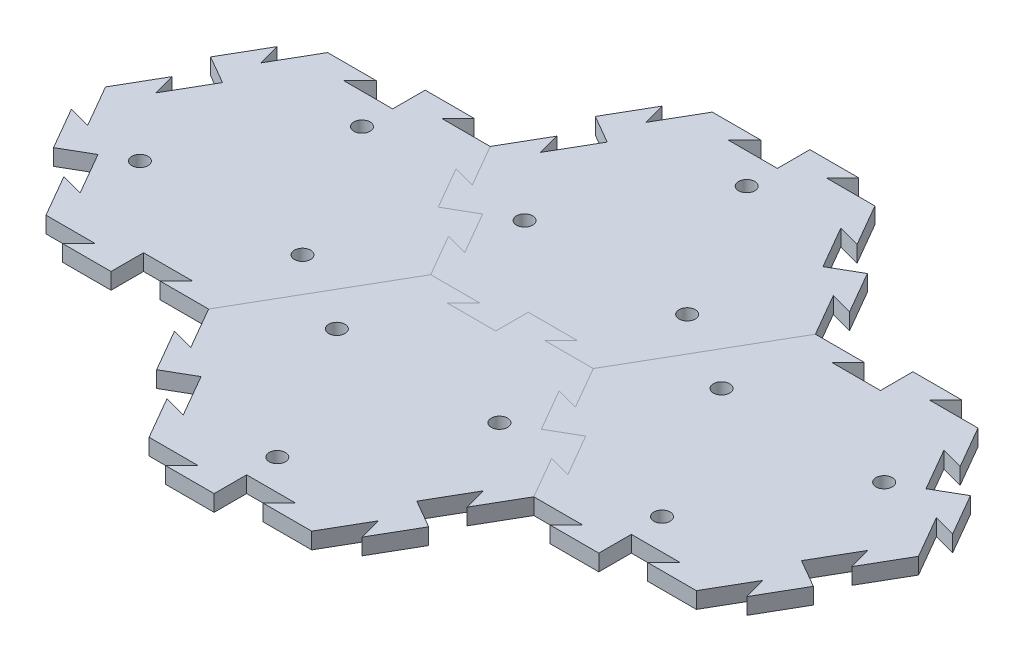
from build123d import *

# Parameters (mm, degrees)
BOSS_EXTRUDE1_DEPTH = 6.35
SKETCH9_R           = 3.175
CUT_EXTRUDE3_DEPTH  = 85.242269675
CIRPATTERN6_COUNT   = 3
CUT_EXTRUDE4_DEPTH  = 194.232075495
BOSS_EXTRUDE4_DEPTH = 6.35
CIRPATTERN7_COUNT   = 6
CUT_EXTRUDE5_DEPTH  = 194.232075495
BOSS_EXTRUDE5_DEPTH = 6.35
CIRPATTERN8_COUNT   = 6
LPATTERN1_COUNT     = 2
LPATTERN1_PITCH     = 109.985226308


with BuildPart() as part:
    # Sketch1 → Boss-Extrude1 (new body)
    with BuildSketch(Plane(origin=(0, 0, 0), x_dir=(1, 0, 0), z_dir=(0, 1, 0))):
        Polygon((63.5, 0), (31.75, 54.99261314), (-31.75, 54.99261314), (-63.5, 0), (-31.75, -54.99261314), (31.75, -54.99261314), align=None)
    extrude(amount=-BOSS_EXTRUDE1_DEPTH)

    # Sketch9 → Cut-Extrude3 (cut, through all)
    with BuildSketch(Plane(origin=(0, 0, 0), x_dir=(1, 0, 0), z_dir=(0, 1, 0))):
        with Locations((-31.75, -18.330871047)):
            Circle(SKETCH9_R)
    cut_extrude3 = extrude(amount=-CUT_EXTRUDE3_DEPTH, mode=Mode.SUBTRACT)

    # CirPattern6: Cut-Extrude3 ×3 about axis
    cirpattern6_axis = Axis((0, 0, 0), (0, 1, 0))
    for i in range(1, CIRPATTERN6_COUNT):
        add(cut_extrude3.rotate(cirpattern6_axis, i * 360 / CIRPATTERN6_COUNT), mode=Mode.SUBTRACT)


with BuildPart() as body_2:
    # Mirror3: mirrored copy
    add(part.part.mirror(Plane(origin=(31.75, -6.35, 54.99261314), x_dir=(-0.4999999999999997, 0, 0.8660254037844387), z_dir=(0.8660254037844387, 0, 0.49999999999999983))))

    # Sketch13 → Cut-Extrude5 (cut, through all)
    with BuildSketch(Plane(origin=(0, 0, 0), x_dir=(1, 0, 0), z_dir=(0, 1, 0))):
        Polygon((136.525, -16.497783942), (127.850738686, -14.173522628), (137.375738686, -30.67130657), (142.875, -27.49630657), align=None)
    cut_extrude5 = extrude(amount=-CUT_EXTRUDE5_DEPTH, mode=Mode.SUBTRACT)

    # Sketch14 → Boss-Extrude5 (add)
    with BuildSketch(Plane(origin=(0, 0, 0), x_dir=(1, 0, 0), z_dir=(0, 1, 0))):
        Polygon((142.875, -27.49630657), (148.374261314, -24.32130657), (157.899261314, -40.819090512), (149.225, -38.494829198), align=None)
    boss_extrude5 = extrude(amount=-BOSS_EXTRUDE5_DEPTH)

    # CirPattern8: Cut-Extrude5, Boss-Extrude5 ×6 about axis, 1 skipped
    cirpattern8_axis = Axis((95.25, 0, 54.99261314), (0, 1, 0))
    add([cut_extrude5.rotate(cirpattern8_axis, i * 360 / CIRPATTERN8_COUNT) for i in range(1, CIRPATTERN8_COUNT) if i not in (2,)], mode=Mode.SUBTRACT)
    add([boss_extrude5.rotate(cirpattern8_axis, i * 360 / CIRPATTERN8_COUNT) for i in range(1, CIRPATTERN8_COUNT) if i not in (2,)])


with BuildPart() as part_1:
    add(part.part)

    # Sketch10 → Cut-Extrude4 (cut, through all)
    with BuildSketch(Plane(origin=(0, 0, 0), x_dir=(1, 0, 0), z_dir=(0, 1, 0))):
        Polygon((41.275, 38.494829198), (32.600738686, 40.819090512), (42.125738686, 24.32130657), (47.625, 27.49630657), align=None)
    cut_extrude4 = extrude(amount=-CUT_EXTRUDE4_DEPTH, mode=Mode.SUBTRACT)

    # Sketch11 → Boss-Extrude4 (add)
    with BuildSketch(Plane(origin=(0, 0, 0), x_dir=(1, 0, 0), z_dir=(0, 1, 0))):
        Polygon((47.625, 27.49630657), (53.124261314, 30.67130657), (62.649261314, 14.173522628), (53.975, 16.497783942), align=None)
    boss_extrude4 = extrude(amount=-BOSS_EXTRUDE4_DEPTH)

    # CirPattern7: Cut-Extrude4, Boss-Extrude4 ×6 about axis, 1 skipped
    cirpattern7_axis = Axis((0, 0, 0), (0, 1, 0))
    add([cut_extrude4.rotate(cirpattern7_axis, i * 360 / CIRPATTERN7_COUNT) for i in range(1, CIRPATTERN7_COUNT) if i not in (5,)], mode=Mode.SUBTRACT)
    add([boss_extrude4.rotate(cirpattern7_axis, i * 360 / CIRPATTERN7_COUNT) for i in range(1, CIRPATTERN7_COUNT) if i not in (5,)])


with BuildPart() as lpattern1_1:
    # LPattern1: pattern copy
    add(part_1.part.moved(Location(Vector(0.8660254037844387, 0, -0.49999999999999994) * (1 * LPATTERN1_PITCH))))


with BuildPart() as lpattern1_2:
    # LPattern1: pattern copy
    add(body_2.part.moved(Location(Vector(0.8660254037844387, 0, -0.49999999999999994) * (1 * LPATTERN1_PITCH))))


solid = Compound([body_2.part, part_1.part, lpattern1_1.part, lpattern1_2.part])
